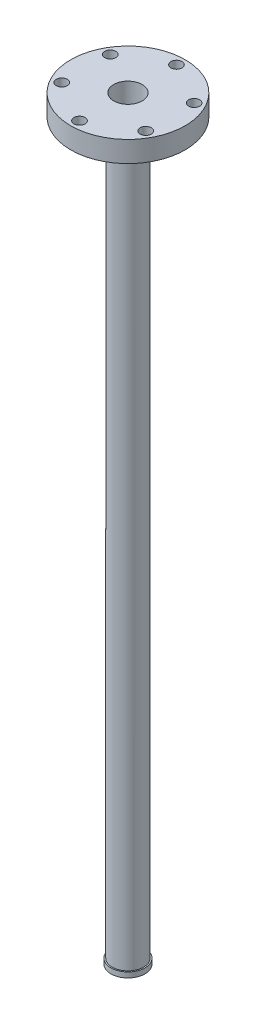
from build123d import *

# Parameters (mm, degrees)
SKETCH1_R         = 9.525
SKETCH1_R_2       = 8.636
EXTRUDE1_DEPTH    = 457.2
SKETCH2_R         = 34.671
SKETCH2_R_2       = 8.636
EXTRUDE2_DEPTH    = 12.7
SKETCH3_R         = 3.3655
EXTRUDE3_DEPTH    = 458.2
CIRPATTERN1_COUNT = 6
SKETCH4_R         = 10.31875
SKETCH4_R_2       = 8.636
EXTRUDE4_DEPTH    = 3.175


with BuildPart() as part:
    # Sketch1 → Extrude1 (new body)
    with BuildSketch(Plane(origin=(0, 0, 0), x_dir=(1, 0, 0), z_dir=(0, 1, 0))):
        Circle(SKETCH1_R)
        Circle(SKETCH1_R_2, mode=Mode.SUBTRACT)
    extrude(amount=EXTRUDE1_DEPTH)

    # Sketch2 → Extrude2 (add)
    with BuildSketch(Plane(origin=(0, 457.2, 0), x_dir=(1, 0, 0), z_dir=(0, 1, 0))):
        Circle(SKETCH2_R)
        Circle(SKETCH2_R_2, mode=Mode.SUBTRACT)
    extrude(amount=-EXTRUDE2_DEPTH)

    # Sketch3 → Extrude3 (cut, through all)
    with BuildSketch(Plane(origin=(0, 457.2, 0), x_dir=(1, 0, 0), z_dir=(0, 1, 0))):
        with Locations((0, 29.3624)):
            Circle(SKETCH3_R)
    extrude3 = extrude(amount=-EXTRUDE3_DEPTH, mode=Mode.SUBTRACT)

    # CirPattern1: Extrude3 ×6 about axis
    cirpattern1_axis = Axis((0, 0, 0), (0, 1, 0))
    for i in range(1, CIRPATTERN1_COUNT):
        add(extrude3.rotate(cirpattern1_axis, i * 360 / CIRPATTERN1_COUNT), mode=Mode.SUBTRACT)

    # Sketch4 → Extrude4 (add)
    with BuildSketch(Plane.XZ):
        Circle(SKETCH4_R)
        Circle(SKETCH4_R_2, mode=Mode.SUBTRACT)
    extrude(amount=-EXTRUDE4_DEPTH)


solid = part.part
